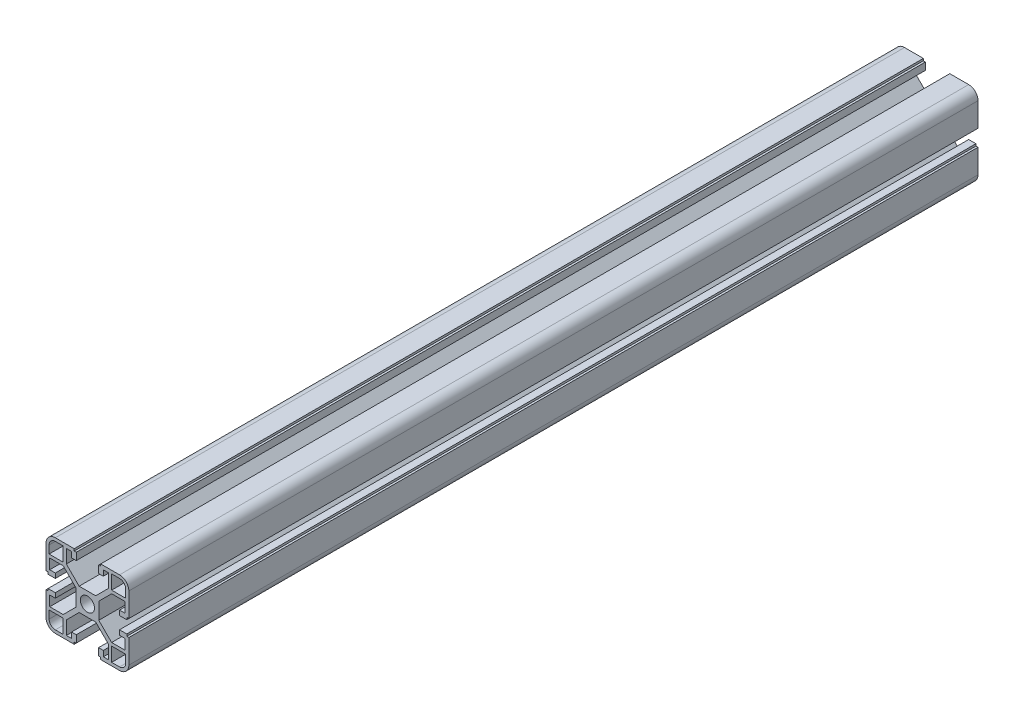
from build123d import *

# Parameters (mm, degrees)
BOSS_EXTRUDE1_DEPTH  = 410
MIRROR3_COPY_1_DEPTH = 410
MIRROR3_COPY_2_DEPTH = 410


with BuildPart() as part:
    # Sketch1 → Boss-Extrude1 (new body)
    with BuildSketch(Plane.XY):
        with BuildLine():
            Line((3.4, 0), (5.5, 0))
            Line((5.5, 0), (5.5, 4))
            Line((5.5, 4), (11.69, 10.19))
            Line((11.69, 10.19), (18.2, 10.19))
            Line((18.2, 10.19), (18.2, 5.265595036))
            Line((18.2, 5.265595036), (15.5, 5.265595036))
            Line((15.5, 5.265595036), (15.5, 2.965595036))
            Line((15.5, 2.965595036), (19, 2.965595036))
            Line((19, 2.965595036), (19, 3.965595036))
            Line((19, 3.965595036), (20, 3.965595036))
            Line((20, 3.965595036), (20, 15.5))
            ThreePointArc((20, 15.5), (18.681980515, 18.681980515), (15.5, 20))
            Line((15.5, 20), (6.385304712, 20))
            Line((6.385304712, 20), (6.385304712, 19))
            Line((6.385304712, 19), (5.385304712, 19))
            Line((5.385304712, 19), (5.385304712, 15.5))
            Line((5.385304712, 15.5), (7.685304712, 15.5))
            Line((7.685304712, 15.5), (7.685304712, 18.2))
            Line((7.685304712, 18.2), (10.19, 18.2))
            Line((10.19, 18.2), (10.19, 11.69))
            Line((10.19, 11.69), (4, 5.5))
            Line((4, 5.5), (0, 5.5))
            Line((0, 5.5), (0, 3.4))
            ThreePointArc((0, 3.4), (2.404163056, 2.404163056), (3.4, 0))
        make_face()
        with BuildLine():
            Line((18.5, 11.69), (18.5, 15.5))
            ThreePointArc((18.5, 15.5), (17.621320344, 17.621320344), (15.5, 18.5))
            Line((15.5, 18.5), (11.69, 18.5))
            Line((11.69, 18.5), (11.69, 11.69))
            Line((11.69, 11.69), (18.5, 11.69))
        make_face(mode=Mode.SUBTRACT)
    boss_extrude1 = extrude(amount=BOSS_EXTRUDE1_DEPTH)

    # Mirror1: Boss-Extrude1 across plane
    add(boss_extrude1.mirror(Plane.ZX))

    # Mirror2: Boss-Extrude1 across plane
    add(boss_extrude1.mirror(Plane(origin=(0, 0, 0), x_dir=(0, 0, 1), z_dir=(1, 0, 0))))

    # Mirror3 copy 1 sketch → Mirror3 copy 1 (add)
    with BuildSketch(Plane(origin=(0, 0, 0), x_dir=(-1, 0, 0), z_dir=(0, 0, 1))):
        with BuildLine():
            Line((3.4, 0), (5.5, 0))
            Line((5.5, 0), (5.5, 4))
            Line((5.5, 4), (11.69, 10.19))
            Line((11.69, 10.19), (18.2, 10.19))
            Line((18.2, 10.19), (18.2, 5.265595036))
            Line((18.2, 5.265595036), (15.5, 5.265595036))
            Line((15.5, 5.265595036), (15.5, 2.965595036))
            Line((15.5, 2.965595036), (19, 2.965595036))
            Line((19, 2.965595036), (19, 3.965595036))
            Line((19, 3.965595036), (20, 3.965595036))
            Line((20, 3.965595036), (20, 15.5))
            ThreePointArc((20, 15.5), (18.681980515, 18.681980515), (15.5, 20))
            Line((15.5, 20), (6.385304712, 20))
            Line((6.385304712, 20), (6.385304712, 19))
            Line((6.385304712, 19), (5.385304712, 19))
            Line((5.385304712, 19), (5.385304712, 15.5))
            Line((5.385304712, 15.5), (7.685304712, 15.5))
            Line((7.685304712, 15.5), (7.685304712, 18.2))
            Line((7.685304712, 18.2), (10.19, 18.2))
            Line((10.19, 18.2), (10.19, 11.69))
            Line((10.19, 11.69), (4, 5.5))
            Line((4, 5.5), (0, 5.5))
            Line((0, 5.5), (0, 3.4))
            ThreePointArc((0, 3.4), (2.404163056, 2.404163056), (3.4, 0))
        make_face()
        with BuildLine():
            Line((18.5, 11.69), (18.5, 15.5))
            ThreePointArc((18.5, 15.5), (17.621320344, 17.621320344), (15.5, 18.5))
            Line((15.5, 18.5), (11.69, 18.5))
            Line((11.69, 18.5), (11.69, 11.69))
            Line((11.69, 11.69), (18.5, 11.69))
        make_face(mode=Mode.SUBTRACT)
    extrude(amount=MIRROR3_COPY_1_DEPTH)

    # Mirror3 copy 2 sketch → Mirror3 copy 2 (add)
    with BuildSketch(Plane.XY):
        with BuildLine():
            Line((3.4, 0), (5.5, 0))
            Line((5.5, 0), (5.5, -4))
            Line((5.5, -4), (11.69, -10.19))
            Line((11.69, -10.19), (18.2, -10.19))
            Line((18.2, -10.19), (18.2, -5.265595036))
            Line((18.2, -5.265595036), (15.5, -5.265595036))
            Line((15.5, -5.265595036), (15.5, -2.965595036))
            Line((15.5, -2.965595036), (19, -2.965595036))
            Line((19, -2.965595036), (19, -3.965595036))
            Line((19, -3.965595036), (20, -3.965595036))
            Line((20, -3.965595036), (20, -15.5))
            ThreePointArc((20, -15.5), (18.681980515, -18.681980515), (15.5, -20))
            Line((15.5, -20), (6.385304712, -20))
            Line((6.385304712, -20), (6.385304712, -19))
            Line((6.385304712, -19), (5.385304712, -19))
            Line((5.385304712, -19), (5.385304712, -15.5))
            Line((5.385304712, -15.5), (7.685304712, -15.5))
            Line((7.685304712, -15.5), (7.685304712, -18.2))
            Line((7.685304712, -18.2), (10.19, -18.2))
            Line((10.19, -18.2), (10.19, -11.69))
            Line((10.19, -11.69), (4, -5.5))
            Line((4, -5.5), (0, -5.5))
            Line((0, -5.5), (0, -3.4))
            ThreePointArc((0, -3.4), (2.404163056, -2.404163056), (3.4, 0))
        make_face()
        with BuildLine():
            Line((18.5, -11.69), (18.5, -15.5))
            ThreePointArc((18.5, -15.5), (17.621320344, -17.621320344), (15.5, -18.5))
            Line((15.5, -18.5), (11.69, -18.5))
            Line((11.69, -18.5), (11.69, -11.69))
            Line((11.69, -11.69), (18.5, -11.69))
        make_face(mode=Mode.SUBTRACT)
    extrude(amount=MIRROR3_COPY_2_DEPTH)


solid = part.part
